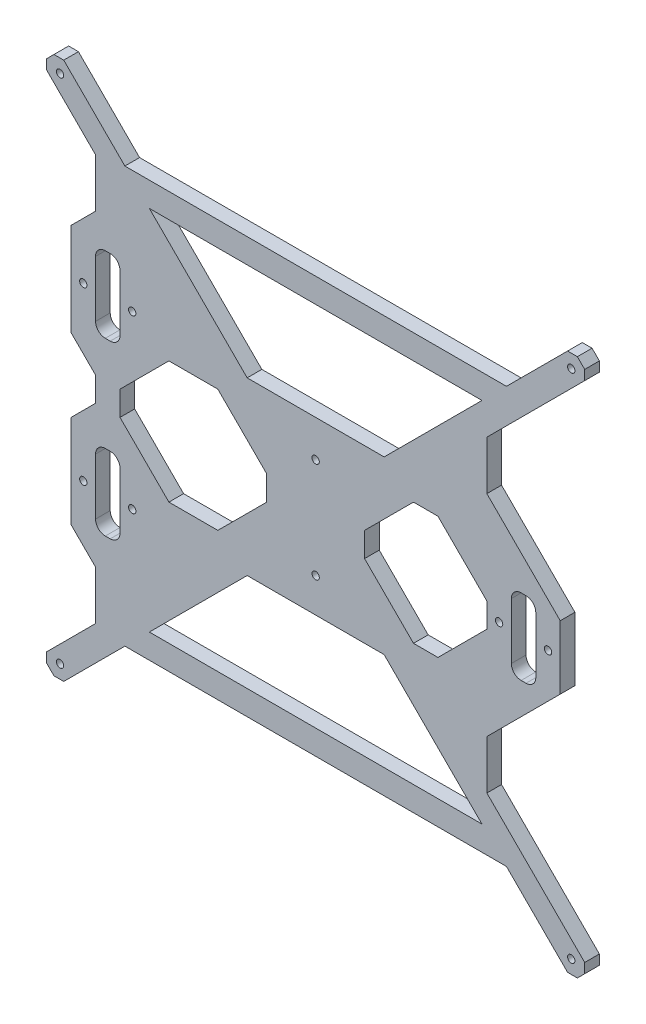
from build123d import *

# Parameters (mm, degrees)
MODEL_R                  = 1.5
RESSALTO_EXTRUS_O1_DEPTH = 6


with BuildPart() as part:
    # Model → Ressalto-extrusão1 (new body)
    with BuildSketch(Plane.XY):
        Polygon((27.223932907, 227.848775031), (25.223932907, 227.848775031), (22.223932907, 224.848775031), (22.223932907, 222.848775031), (22.223932907, 220.848775031), (42.223932907, 200.848775031), (42.223932907, 180.848775031), (32.223932907, 170.848775031), (32.223932907, 132.848775031), (42.223932907, 122.848775031), (42.223932907, 112.848775031), (32.223932907, 102.848775031), (32.223932907, 64.848775031), (42.223932907, 54.848775031), (42.223932907, 34.848775031), (22.223932907, 14.848775031), (22.223932907, 10.848775031), (25.223932907, 7.848775031), (27.223932907, 7.848775031), (29.223932907, 7.848775031), (54.223932907, 32.848775031), (210.223932907, 32.848775031), (235.223932907, 7.848775031), (237.223932907, 7.848775031), (239.223932907, 7.848775031), (242.223932907, 10.848775031), (242.223932907, 14.848775031), (222.223932907, 34.848775031), (202.223932907, 54.848775031), (202.223932907, 74.848775031), (222.223932907, 94.848775031), (232.223932907, 104.848775031), (232.223932907, 130.848775031), (222.223932907, 140.848775031), (202.223932907, 160.848775031), (202.223932907, 180.848775031), (242.223932907, 220.848775031), (242.223932907, 223.848775031), (242.223932907, 224.848775031), (239.223932907, 227.848775031), (235.223932907, 227.848775031), (212.223932907, 204.848775031), (210.223932907, 202.848775031), (54.223932907, 202.848775031), (29.223932907, 227.848775031), align=None)
        with Locations((37.223932907, 152.848775031)):
            Circle(MODEL_R, mode=Mode.SUBTRACT)
        with Locations((57.223932907, 152.848775031)):
            Circle(MODEL_R, mode=Mode.SUBTRACT)
        with Locations((37.223932907, 82.848775031)):
            Circle(MODEL_R, mode=Mode.SUBTRACT)
        with Locations((57.223932907, 82.848775031)):
            Circle(MODEL_R, mode=Mode.SUBTRACT)
        with Locations((227.223932907, 117.848775031)):
            Circle(MODEL_R, mode=Mode.SUBTRACT)
        with Locations((207.223932907, 117.848775031)):
            Circle(MODEL_R, mode=Mode.SUBTRACT)
        with Locations((27.723932907, 222.348775031)):
            Circle(MODEL_R, mode=Mode.SUBTRACT)
        with Locations((236.723932907, 13.348775031)):
            Circle(MODEL_R, mode=Mode.SUBTRACT)
        with Locations((236.723932907, 222.348775031)):
            Circle(MODEL_R, mode=Mode.SUBTRACT)
        with Locations((27.723932907, 13.348775031)):
            Circle(MODEL_R, mode=Mode.SUBTRACT)
        with Locations((132.223932907, 96.848775031)):
            Circle(MODEL_R, mode=Mode.SUBTRACT)
        with Locations((132.223932907, 137.848775031)):
            Circle(MODEL_R, mode=Mode.SUBTRACT)
        Polygon((172.223932907, 164.848775031), (170.223932907, 162.848775031), (160.223932907, 152.848775031), (104.223932907, 152.848775031), (64.223932907, 192.848775031), (200.223932907, 192.848775031), align=None, mode=Mode.SUBTRACT)
        Polygon((160.223932907, 82.848775031), (104.223932907, 82.848775031), (64.223932907, 42.848775031), (200.223932907, 42.848775031), align=None, mode=Mode.SUBTRACT)
        Polygon((52.223932907, 122.848775031), (72.223932907, 142.848775031), (92.223932907, 142.848775031), (112.223932907, 122.848775031), (112.223932907, 112.848775031), (92.223932907, 92.848775031), (72.223932907, 92.848775031), (52.223932907, 112.848775031), align=None, mode=Mode.SUBTRACT)
        Polygon((182.223932907, 142.848775031), (202.223932907, 122.848775031), (202.223932907, 112.848775031), (182.223932907, 92.848775031), (172.223932907, 92.848775031), (152.223932907, 112.848775031), (152.223932907, 122.848775031), (172.223932907, 142.848775031), align=None, mode=Mode.SUBTRACT)
        with BuildLine():
            Line((42.223932907, 71.848775031), (42.223932907, 94.848775031))
            ThreePointArc((42.223932907, 94.848775031), (43.395505782, 97.677202156), (46.223932907, 98.848775031))
            Line((46.223932907, 98.848775031), (48.223932907, 98.848775031))
            ThreePointArc((48.223932907, 98.848775031), (51.052360031, 97.677202156), (52.223932907, 94.848775031))
            Line((52.223932907, 94.848775031), (52.223932907, 71.848775031))
            ThreePointArc((52.223932907, 71.848775031), (51.052360031, 69.020347906), (48.223932907, 67.848775031))
            Line((48.223932907, 67.848775031), (46.223932907, 67.848775031))
            ThreePointArc((46.223932907, 67.848775031), (43.395505782, 69.020347906), (42.223932907, 71.848775031))
        make_face(mode=Mode.SUBTRACT)
        with BuildLine():
            Line((42.223932907, 141.855811927), (42.223932907, 164.855811927))
            ThreePointArc((42.223932907, 164.855811927), (43.395505782, 167.684239052), (46.223932907, 168.855811927))
            Line((46.223932907, 168.855811927), (48.223932907, 168.855811927))
            ThreePointArc((48.223932907, 168.855811927), (51.052360031, 167.684239052), (52.223932907, 164.855811927))
            Line((52.223932907, 164.855811927), (52.223932907, 141.855811927))
            ThreePointArc((52.223932907, 141.855811927), (51.052360031, 139.027384802), (48.223932907, 137.855811927))
            Line((48.223932907, 137.855811927), (46.223932907, 137.855811927))
            ThreePointArc((46.223932907, 137.855811927), (43.395505782, 139.027384802), (42.223932907, 141.855811927))
        make_face(mode=Mode.SUBTRACT)
        with BuildLine():
            Line((212.223932907, 105.711651424), (212.223932907, 128.711651424))
            ThreePointArc((212.223932907, 128.711651424), (213.395505782, 131.540078549), (216.223932907, 132.711651424))
            Line((216.223932907, 132.711651424), (218.223932907, 132.711651424))
            ThreePointArc((218.223932907, 132.711651424), (221.052360031, 131.540078549), (222.223932907, 128.711651424))
            Line((222.223932907, 128.711651424), (222.223932907, 105.711651424))
            ThreePointArc((222.223932907, 105.711651424), (221.052360031, 102.883224299), (218.223932907, 101.711651424))
            Line((218.223932907, 101.711651424), (216.223932907, 101.711651424))
            ThreePointArc((216.223932907, 101.711651424), (213.395505782, 102.883224299), (212.223932907, 105.711651424))
        make_face(mode=Mode.SUBTRACT)
    extrude(amount=RESSALTO_EXTRUS_O1_DEPTH)


solid = part.part
